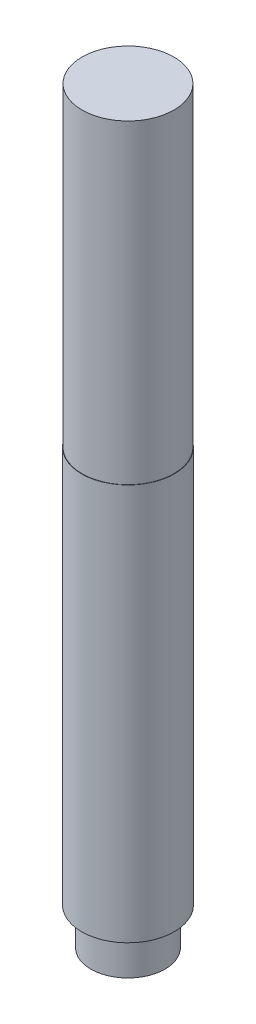
from build123d import *

# Parameters (mm, degrees)
SKETCH1_R           = 12.5
BOSS_EXTRUDE1_DEPTH = 107
SKETCH2_R           = 12.4
BOSS_EXTRUDE2_DEPTH = 85
SKETCH3_R           = 10
BOSS_EXTRUDE3_DEPTH = 10


with BuildPart() as part:
    # Sketch1 → Boss-Extrude1 (new body)
    with BuildSketch(Plane(origin=(0, 0, 0), x_dir=(1, 0, 0), z_dir=(0, 1, 0))):
        Circle(SKETCH1_R)
    extrude(amount=BOSS_EXTRUDE1_DEPTH)

    # Sketch2 → Boss-Extrude2 (add)
    with BuildSketch(Plane(origin=(0, 107, 0), x_dir=(1, 0, 0), z_dir=(0, 1, 0))):
        Circle(SKETCH2_R)
    extrude(amount=BOSS_EXTRUDE2_DEPTH)

    # Sketch3 → Boss-Extrude3 (add)
    with BuildSketch(Plane.XZ):
        Circle(SKETCH3_R)
    extrude(amount=BOSS_EXTRUDE3_DEPTH)


solid = part.part
